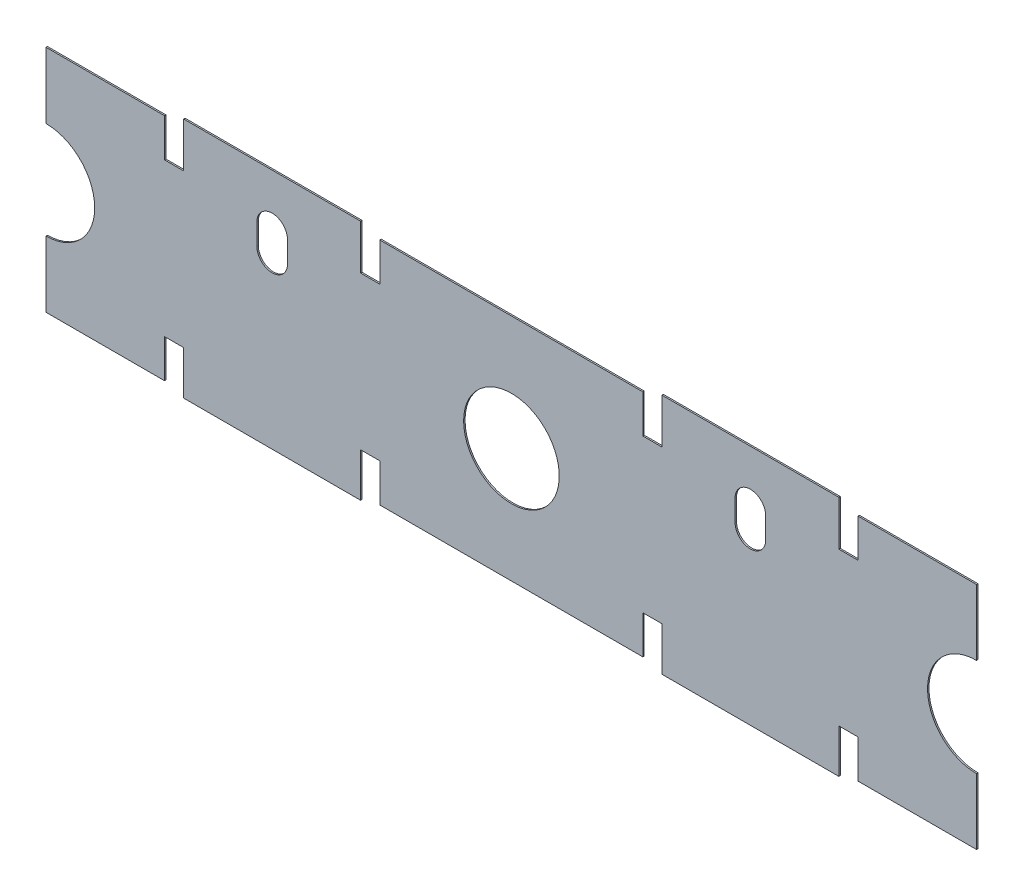
from build123d import *

# Parameters (mm, degrees)
SKETCH_1_R      = 5
EXTRUDE_1_DEPTH = 0.15


with BuildPart() as part:
    # Эскиз1 → Бобышка-Вытянуть1 (new body)
    with BuildSketch(Plane(origin=(0, 0, 0), x_dir=(-1, 0, 0), z_dir=(0, 0, -1))):
        with BuildLine():
            Line((-94.25, 76.699996948), (-94.25, 72))
            Line((-94.25, 72), (-96.25, 72))
            Line((-96.25, 72), (-96.25, 76))
            Line((-96.25, 76), (-108.650001526, 76))
            Line((-108.650001526, 76), (-108.650001526, 69.126998901))
            ThreePointArc((-108.650001526, 69.126998901), (-103.523002625, 64), (-108.650001526, 58.873001099))
            Line((-108.650001526, 58.873001099), (-108.650001526, 52))
            Line((-108.650001526, 52), (-96.25, 52))
            Line((-96.25, 52), (-96.25, 56))
            Line((-96.25, 56), (-94.25, 56))
            Line((-94.25, 56), (-94.25, 51.424999237))
            Line((-94.25, 51.424999237), (-75.75, 51.424999237))
            Line((-75.75, 51.424999237), (-75.75, 56))
            Line((-75.75, 56), (-73.75, 56))
            Line((-73.75, 56), (-73.75, 52))
            Line((-73.75, 52), (-46.25, 52))
            Line((-46.25, 52), (-46.25, 56))
            Line((-46.25, 56), (-44.25, 56))
            Line((-44.25, 56), (-44.25, 51.424999237))
            Line((-44.25, 51.424999237), (-25.75, 51.424999237))
            Line((-25.75, 51.424999237), (-25.75, 56))
            Line((-25.75, 56), (-23.75, 56))
            Line((-23.75, 56), (-23.75, 52))
            Line((-23.75, 52), (-11.350000381, 52))
            Line((-11.350000381, 52), (-11.350000381, 58.909999847))
            ThreePointArc((-11.350000381, 58.909999847), (-16.439998627, 63.999998093), (-11.350000381, 69.089996338))
            Line((-11.350000381, 69.089996338), (-11.350000381, 76))
            Line((-11.350000381, 76), (-23.75, 76))
            Line((-23.75, 76), (-23.75, 72))
            Line((-23.75, 72), (-25.75, 72))
            Line((-25.75, 72), (-25.75, 76.699996948))
            Line((-25.75, 76.699996948), (-44.25, 76.699996948))
            Line((-44.25, 76.699996948), (-44.25, 72))
            Line((-44.25, 72), (-46.25, 72))
            Line((-46.25, 72), (-46.25, 76))
            Line((-46.25, 76), (-73.75, 76))
            Line((-73.75, 76), (-73.75, 72))
            Line((-73.75, 72), (-75.75, 72))
            Line((-75.75, 72), (-75.75, 76.699996948))
            Line((-75.75, 76.699996948), (-94.25, 76.699996948))
        make_face()
        with Locations((-60.017142334, 64)):
            Circle(SKETCH_1_R, mode=Mode.SUBTRACT)
        with BuildLine():
            Line((-33.400001526, 68.999998474), (-33.400001526, 71.199998474))
            ThreePointArc((-33.400001526, 71.199998474), (-35, 72.799996948), (-36.599998474, 71.199998474))
            Line((-36.599998474, 71.199998474), (-36.599998474, 68.999998474))
            ThreePointArc((-36.599998474, 68.999998474), (-35, 67.4), (-33.400001526, 68.999998474))
        make_face(mode=Mode.SUBTRACT)
        with BuildLine():
            Line((-83.400001526, 71.199998474), (-83.400001526, 68.999998474))
            ThreePointArc((-83.400001526, 68.999998474), (-85, 67.4), (-86.599998474, 68.999998474))
            Line((-86.599998474, 68.999998474), (-86.599998474, 71.199998474))
            ThreePointArc((-86.599998474, 71.199998474), (-85, 72.799996948), (-83.400001526, 71.199998474))
        make_face(mode=Mode.SUBTRACT)
    extrude(amount=-EXTRUDE_1_DEPTH)


solid = part.part
